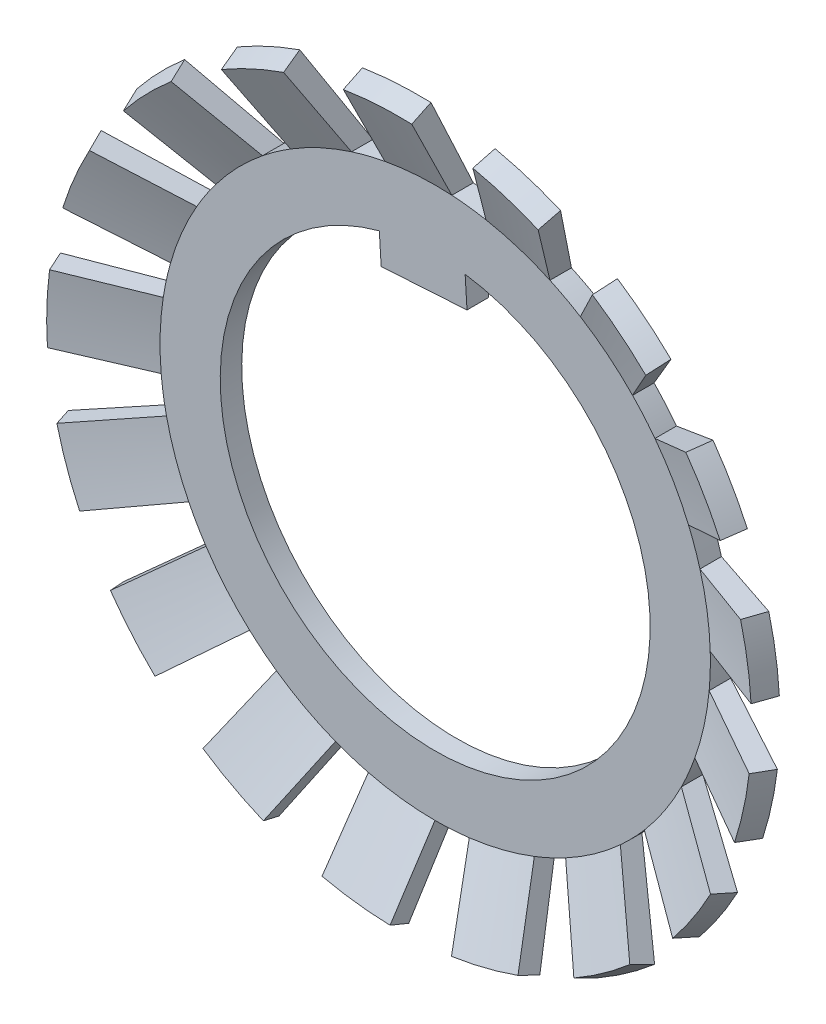
from build123d import *

# Parameters (mm, degrees)
SKETCH2_OUTSIDE_W        = 55.898
SKETCH2_OUTSIDE_H        = 55.898
SKETCH2_OUTSIDE_R        = 12.5
CUT_EXTRUDE_DEPTH        = 4.346553008
PATTERN_CIRCULAR_4_COUNT = 17
EXTRUDE_1_DEPTH          = 1.25


with BuildPart() as part:
    # Sketch1 → Base-Extrude (revolve)
    with BuildSketch(Plane.YZ):
        Polygon((0, -3.346553008), (-16, -3.346553008), (-21, -1.143921767), (-20.496072436, 0), (-16, -2.096553008), (0, -2.096553008), align=None)
    revolve(axis=Axis((0, 0, 5.823648763), (0, 0, -1)))

    # Sketch2 outside → Cut-Extrude (cut, through all)
    with BuildSketch(Plane(origin=(-2.40435344, 1.003568156, -3.346553008), x_dir=(-1, 0, 0), z_dir=(0, 0, -1))):
        with Locations((-2.404, -1.004)):
            Rectangle(SKETCH2_OUTSIDE_W, SKETCH2_OUTSIDE_H)
        with BuildLine():
            Line((-15.182466724, 8.625545038), (-19.50954274, 11.178898713))
            ThreePointArc((-19.50954274, 11.178898713), (-20.590886919, 9.496431844), (-21.507273879, 7.718726879))
            Line((-21.507273879, 7.718726879), (-17.132466724, 5.248045963))
            ThreePointArc((-17.132466724, 5.248045963), (11.452053021, -9.003568156), (-15.182466724, 8.625545038))
        make_face(mode=Mode.SUBTRACT)
        with Locations((-2.40435344, -1.003568156)):
            Circle(SKETCH2_OUTSIDE_R)
    extrude(amount=-CUT_EXTRUDE_DEPTH, mode=Mode.SUBTRACT)


with BuildPart() as pattern_circular_4_1:
    # 阵列(圆周)4: pattern copy
    add(part.part.rotate(Axis((0, 0, 0), (0, 0, 1)), 1 * 360 / PATTERN_CIRCULAR_4_COUNT))


with BuildPart() as pattern_circular_4_2:
    # 阵列(圆周)4: pattern copy
    add(part.part.rotate(Axis((0, 0, 0), (0, 0, 1)), 2 * 360 / PATTERN_CIRCULAR_4_COUNT))


with BuildPart() as pattern_circular_4_3:
    # 阵列(圆周)4: pattern copy
    add(part.part.rotate(Axis((0, 0, 0), (0, 0, 1)), 3 * 360 / PATTERN_CIRCULAR_4_COUNT))


with BuildPart() as pattern_circular_4_4:
    # 阵列(圆周)4: pattern copy
    add(part.part.rotate(Axis((0, 0, 0), (0, 0, 1)), 4 * 360 / PATTERN_CIRCULAR_4_COUNT))


with BuildPart() as pattern_circular_4_5:
    # 阵列(圆周)4: pattern copy
    add(part.part.rotate(Axis((0, 0, 0), (0, 0, 1)), 5 * 360 / PATTERN_CIRCULAR_4_COUNT))


with BuildPart() as pattern_circular_4_6:
    # 阵列(圆周)4: pattern copy
    add(part.part.rotate(Axis((0, 0, 0), (0, 0, 1)), 6 * 360 / PATTERN_CIRCULAR_4_COUNT))


with BuildPart() as pattern_circular_4_7:
    # 阵列(圆周)4: pattern copy
    add(part.part.rotate(Axis((0, 0, 0), (0, 0, 1)), 7 * 360 / PATTERN_CIRCULAR_4_COUNT))


with BuildPart() as pattern_circular_4_8:
    # 阵列(圆周)4: pattern copy
    add(part.part.rotate(Axis((0, 0, 0), (0, 0, 1)), 8 * 360 / PATTERN_CIRCULAR_4_COUNT))


with BuildPart() as pattern_circular_4_9:
    # 阵列(圆周)4: pattern copy
    add(part.part.rotate(Axis((0, 0, 0), (0, 0, 1)), 9 * 360 / PATTERN_CIRCULAR_4_COUNT))


with BuildPart() as pattern_circular_4_10:
    # 阵列(圆周)4: pattern copy
    add(part.part.rotate(Axis((0, 0, 0), (0, 0, 1)), 10 * 360 / PATTERN_CIRCULAR_4_COUNT))


with BuildPart() as pattern_circular_4_11:
    # 阵列(圆周)4: pattern copy
    add(part.part.rotate(Axis((0, 0, 0), (0, 0, 1)), 11 * 360 / PATTERN_CIRCULAR_4_COUNT))


with BuildPart() as pattern_circular_4_12:
    # 阵列(圆周)4: pattern copy
    add(part.part.rotate(Axis((0, 0, 0), (0, 0, 1)), 12 * 360 / PATTERN_CIRCULAR_4_COUNT))


with BuildPart() as pattern_circular_4_13:
    # 阵列(圆周)4: pattern copy
    add(part.part.rotate(Axis((0, 0, 0), (0, 0, 1)), 13 * 360 / PATTERN_CIRCULAR_4_COUNT))


with BuildPart() as pattern_circular_4_14:
    # 阵列(圆周)4: pattern copy
    add(part.part.rotate(Axis((0, 0, 0), (0, 0, 1)), 14 * 360 / PATTERN_CIRCULAR_4_COUNT))


with BuildPart() as pattern_circular_4_15:
    # 阵列(圆周)4: pattern copy
    add(part.part.rotate(Axis((0, 0, 0), (0, 0, 1)), 15 * 360 / PATTERN_CIRCULAR_4_COUNT))


with BuildPart() as pattern_circular_4_16:
    # 阵列(圆周)4: pattern copy
    add(part.part.rotate(Axis((0, 0, 0), (0, 0, 1)), 16 * 360 / PATTERN_CIRCULAR_4_COUNT))


with BuildPart() as part_1:
    add(part.part)

    add(pattern_circular_4_1.part)  # 凸台-拉伸1 merges 阵列(圆周)4_1

    add(pattern_circular_4_2.part)  # 凸台-拉伸1 merges 阵列(圆周)4_2

    add(pattern_circular_4_3.part)  # 凸台-拉伸1 merges 阵列(圆周)4_3

    add(pattern_circular_4_4.part)  # 凸台-拉伸1 merges 阵列(圆周)4_4

    add(pattern_circular_4_5.part)  # 凸台-拉伸1 merges 阵列(圆周)4_5

    add(pattern_circular_4_6.part)  # 凸台-拉伸1 merges 阵列(圆周)4_6

    add(pattern_circular_4_7.part)  # 凸台-拉伸1 merges 阵列(圆周)4_7

    add(pattern_circular_4_8.part)  # 凸台-拉伸1 merges 阵列(圆周)4_8

    add(pattern_circular_4_9.part)  # 凸台-拉伸1 merges 阵列(圆周)4_9

    add(pattern_circular_4_10.part)  # 凸台-拉伸1 merges 阵列(圆周)4_10

    add(pattern_circular_4_11.part)  # 凸台-拉伸1 merges 阵列(圆周)4_11

    add(pattern_circular_4_12.part)  # 凸台-拉伸1 merges 阵列(圆周)4_12

    add(pattern_circular_4_13.part)  # 凸台-拉伸1 merges 阵列(圆周)4_13

    add(pattern_circular_4_14.part)  # 凸台-拉伸1 merges 阵列(圆周)4_14

    add(pattern_circular_4_15.part)  # 凸台-拉伸1 merges 阵列(圆周)4_15

    add(pattern_circular_4_16.part)  # 凸台-拉伸1 merges 阵列(圆周)4_16
    # 草图2 → 凸台-拉伸1 (add)
    with BuildSketch(Plane.XY.offset(-2.096553008)):
        with BuildLine():
            Line((1.848868807, 10.633987217), (1.741294281, 12.378121595))
            ThreePointArc((1.741294281, 12.378121595), (-0.769511327, 12.476291609), (-3.249222363, 12.070317065))
            Line((-3.249222363, 12.070317065), (-3.141647836, 10.326182686))
            Line((-3.141647836, 10.326182686), (1.848868807, 10.633987217))
        make_face()
    extrude(amount=-EXTRUDE_1_DEPTH)


solid = part_1.part
